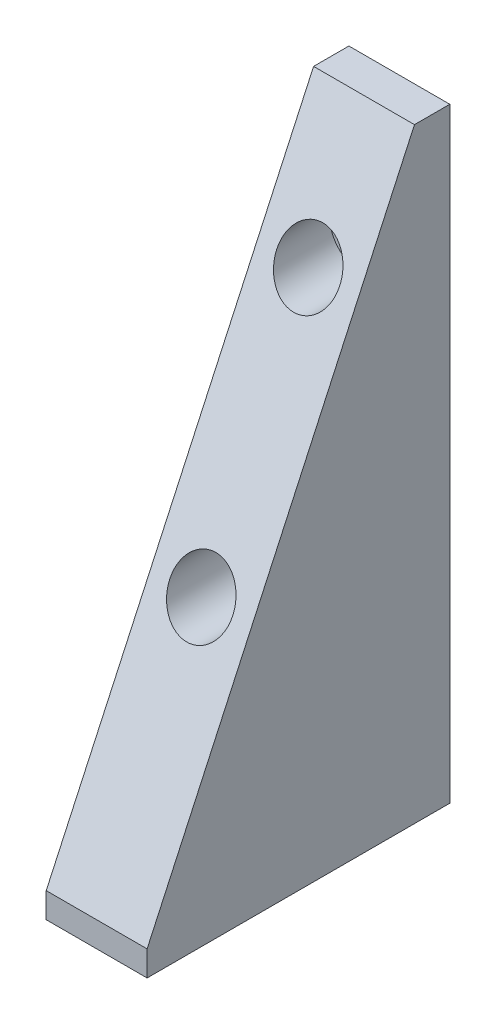
from build123d import *

# Parameters (mm, degrees)
BOSS_EXTRUDE2_DEPTH         = 25.4
CUT_EXTRUDE2_REACH          = 59.15
SKETCH7_R                   = 7.9375
F_3_8_16_TAPPED_HOLE1_D     = 7.9375
F_3_8_16_TAPPED_HOLE1_DEPTH = 25.4
F_3_8_16_TAPPED_HOLE1_TIP   = 2.384665582


with BuildPart() as part:
    # Sketch1 → Boss-Extrude2 (new body)
    with BuildSketch(Plane(origin=(0, 0, 0), x_dir=(0, 0, -1), z_dir=(1, 0, 0))):
        Polygon((21.525976172, 126.619), (-45.784023828, -19.431), (-45.784023828, -25.781), (30.415976172, -25.781), (30.415976172, 126.619), align=None)
    extrude(amount=BOSS_EXTRUDE2_DEPTH)

    # Sketch4 → CBORE for 3/8 Socket Head Cap Screw1 (revolve, cut)
    with BuildSketch(Plane(origin=(12.7, 96.139, -11.365976172), x_dir=(0, -1, 0), z_dir=(1, 0, 0))):
        Polygon((0, 0), (0, 19.05), (4.9022, 19.05), (4.9022, 9.525), (7.9375, 9.525), (7.9375, 0), align=None)
    revolve(axis=Axis((12.7, 96.139, -5.015976172), (0, 0, -1)), mode=Mode.SUBTRACT)

    # Sketch6 → CBORE for 3/8 Socket Head Cap Screw2 (revolve, cut)
    with BuildSketch(Plane(origin=(12.7, 37.719, -10.095976172), x_dir=(0, -1, 0), z_dir=(1, 0, 0))):
        Polygon((0, 0), (0, 20.32), (4.9022, 20.32), (4.9022, 9.525), (7.9375, 9.525), (7.9375, 0), align=None)
    revolve(axis=Axis((12.7, 37.719, -3.745976172), (0, 0, -1)), mode=Mode.SUBTRACT)

    # Sketch7 → Cut-Extrude2 (cut, up to next)
    with BuildSketch(Plane(origin=(0, 96.139, -11.365976172), x_dir=(1, 0, 0), z_dir=(0, 0, 1)), mode=Mode.PRIVATE) as cut_extrude2_sk1:
        with Locations((12.7, -58.42)):
            Circle(SKETCH7_R)
    cut_extrude2_tool1 = extrude(cut_extrude2_sk1.sketch, amount=CUT_EXTRUDE2_REACH, mode=Mode.PRIVATE) & part.part
    add(cut_extrude2_tool1.solids().sort_by_distance((12.7, 37.719, -11.365976))[0], mode=Mode.SUBTRACT)
    # Sketch7 → Cut-Extrude2 (cut, up to next)
    with BuildSketch(Plane(origin=(0, 96.139, -11.365976172), x_dir=(1, 0, 0), z_dir=(0, 0, 1)), mode=Mode.PRIVATE) as cut_extrude2_sk2:
        with Locations((12.7, 0)):
            Circle(SKETCH7_R)
    cut_extrude2_tool2 = extrude(cut_extrude2_sk2.sketch, amount=CUT_EXTRUDE2_REACH, mode=Mode.PRIVATE) & part.part
    add(cut_extrude2_tool2.solids().sort_by_distance((12.7, 96.139, -11.365976))[0], mode=Mode.SUBTRACT)

    # 3/8-16 Tapped Hole1
    with Locations(Plane(origin=(12.7, -25.781, -15.175976172), x_dir=(0, 0, -1), z_dir=(0, -1, 0))):
        with Locations((0, 0), (-40.64, 0)):
            Hole(F_3_8_16_TAPPED_HOLE1_D / 2, depth=F_3_8_16_TAPPED_HOLE1_DEPTH)
            with Locations((0, 0, -(F_3_8_16_TAPPED_HOLE1_DEPTH + F_3_8_16_TAPPED_HOLE1_TIP / 2))):  # 118° drill point
                Cone(0, F_3_8_16_TAPPED_HOLE1_D / 2, F_3_8_16_TAPPED_HOLE1_TIP, mode=Mode.SUBTRACT)


solid = part.part
